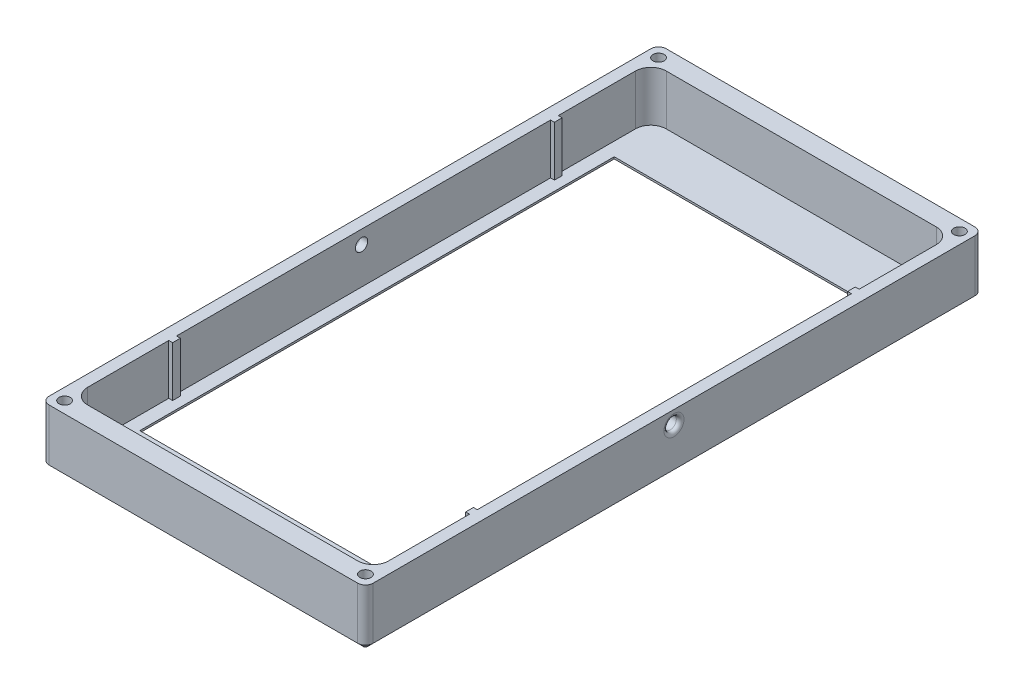
from build123d import *

# Parameters (mm, degrees)
EXTRUDE_2_DEPTH     = 15
FILLET_1_R          = 2
FILLET_2_R          = 2
FILLET_3_R          = 4
FILLET_4_R          = 4
EXTRUDE_3_DEPTH     = 15
FILLET_5_R          = 2
SKETCH_5_R          = 1.45
CUT_EXTRUDE_1_DEPTH = 10
EXTRUDE_4_DEPTH     = 2
SKETCH_9_R          = 1.6
CUT_EXTRUDE_3_DEPTH = 84
FILLET_6_R          = 1
FILLET_7_R          = 1
SKETCH_10_W         = 78
SKETCH_10_H         = 128
SKETCH_10_W_2       = 71
SKETCH_10_H_2       = 123
EXTRUDE_5_DEPTH     = 2
SKETCH_11_W         = 1
SKETCH_11_H         = 2
EXTRUDE_6_DEPTH     = 13
SKETCH_13_R         = 2.45
EXTRUDE_8_DEPTH     = 13
SKETCH_14_W         = 62.39543454
SKETCH_14_H         = 37.793362071
SKETCH_14_H_2       = 37.79336207
CUT_EXTRUDE_4_DEPTH = 15
EXTRUDE_9_DEPTH     = 15
SKETCH_16_R         = 1.45
CUT_EXTRUDE_5_DEPTH = 13
FILLET_8_R          = 2
CHAMFER_1_SIZE      = 1.5


with BuildPart() as part:
    # 草图3 → 凸台-拉伸2 (new body)
    with BuildSketch(Plane(origin=(0, 0, 0), x_dir=(1, 0, 0), z_dir=(0, 1, 0))):
        Polygon((-3, 1345.161797484), (-3, 1501.161797484), (17.145898034, 1501.161797484), (27.145898034, 1521.161797484), (50.854101966, 1521.161797484), (60.854101966, 1501.161797484), (81, 1501.161797484), (81, 1345.161797484), (60.854101966, 1345.161797484), (50.854101966, 1325.161797484), (27.145898034, 1325.161797484), (17.145898034, 1345.161797484), align=None)
        Polygon((49, 1518.161797484), (59, 1498.161797484), (78, 1498.161797484), (78, 1348.161797484), (59, 1348.161797484), (49, 1328.161797484), (29, 1328.161797484), (19, 1348.161797484), (0, 1348.161797484), (0, 1498.161797484), (19, 1498.161797484), (29, 1518.161797484), align=None, mode=Mode.SUBTRACT)
    extrude(amount=EXTRUDE_2_DEPTH)

    # 圆角1
    fillet_1_edges = [part.edges().sort_by_distance(p)[0] for p in [
        (49, 7.5, -1518.161797484),
        (29, 7.5, -1518.161797484),
        (19, 7.5, -1498.161797484),
        (59, 7.5, -1498.161797484),
        (17.145898034, 7.5, -1501.161797484),
        (27.145898034, 7.5, -1521.161797484),
        (50.854101966, 7.5, -1521.161797484),
        (60.854101966, 7.5, -1501.161797484),
    ]]
    fillet(fillet_1_edges, radius=FILLET_1_R)

    # 圆角2
    fillet_2_edges = [part.edges().sort_by_distance(p)[0] for p in [
        (19, 7.5, -1348.161797484),
        (29, 7.5, -1328.161797484),
        (49, 7.5, -1328.161797484),
        (59, 7.5, -1348.161797484),
        (60.854101966, 7.5, -1345.161797484),
        (50.854101966, 7.5, -1325.161797484),
        (27.145898034, 7.5, -1325.161797484),
        (17.145898034, 7.5, -1345.161797484),
    ]]
    fillet(fillet_2_edges, radius=FILLET_2_R)

    # 圆角3
    fillet_3_edges = [part.edges().sort_by_distance(p)[0] for p in [
        (-3, 7.5, -1501.161797484),
        (81, 7.5, -1501.161797484),
        (81, 7.5, -1345.161797484),
        (-3, 7.5, -1345.161797484),
    ]]
    fillet(fillet_3_edges, radius=FILLET_3_R)

    # 圆角4
    fillet_4_edges = [part.edges().sort_by_distance(p)[0] for p in [
        (0, 7.5, -1498.161797484),
        (0, 7.5, -1348.161797484),
        (78, 7.5, -1348.161797484),
        (78, 7.5, -1498.161797484),
    ]]
    fillet(fillet_4_edges, radius=FILLET_4_R)

    # 草图4 → 凸台-拉伸3 (add)
    with BuildSketch(Plane(origin=(0, 15, 0), x_dir=(1, 0, 0), z_dir=(0, 1, 0))):
        with BuildLine():
            Line((8.454915028, 1345.161797484), (22.145898034, 1335.161797484))
            Line((22.145898034, 1335.161797484), (17.698684438, 1344.056224675))
            ThreePointArc((17.698684438, 1344.056224675), (16.96129228, 1344.8630991), (15.909830056, 1345.161797484))
            Line((15.909830056, 1345.161797484), (8.454915028, 1345.161797484))
        make_face()
        with BuildLine():
            Line((69.545084972, 1345.161797484), (62.090169944, 1345.161797484))
            ThreePointArc((62.090169944, 1345.161797484), (61.03870772, 1344.8630991), (60.301315562, 1344.056224675))
            Line((60.301315562, 1344.056224675), (55.854101966, 1335.161797484))
            Line((55.854101966, 1335.161797484), (69.545084972, 1345.161797484))
        make_face()
        with BuildLine():
            Line((69.545084972, 1501.161797484), (55.854101966, 1511.161797484))
            Line((55.854101966, 1511.161797484), (60.301315562, 1502.267370293))
            ThreePointArc((60.301315562, 1502.267370293), (61.03870772, 1501.460495867), (62.090169944, 1501.161797484))
            Line((62.090169944, 1501.161797484), (69.545084972, 1501.161797484))
        make_face()
        with BuildLine():
            Line((8.454915028, 1501.161797484), (15.909830056, 1501.161797484))
            ThreePointArc((15.909830056, 1501.161797484), (16.96129228, 1501.460495867), (17.698684438, 1502.267370293))
            Line((17.698684438, 1502.267370293), (22.145898034, 1511.161797484))
            Line((22.145898034, 1511.161797484), (8.454915028, 1501.161797484))
        make_face()
    extrude(amount=-EXTRUDE_3_DEPTH)

    # 圆角5
    fillet_5_edges = [part.edges().sort_by_distance(p)[0] for p in [
        (8.454915028, 7.5, -1345.161797484),
        (22.145898034, 7.5, -1335.161797484),
        (69.545084972, 7.5, -1345.161797484),
        (55.854101966, 7.5, -1335.161797484),
        (55.854101966, 7.5, -1511.161797484),
        (69.545084972, 7.5, -1501.161797484),
        (8.454915028, 7.5, -1501.161797484),
        (22.145898034, 7.5, -1511.161797484),
    ]]
    fillet(fillet_5_edges, radius=FILLET_5_R)

    # 草图5 → 切除-拉伸1 (cut)
    with BuildSketch(Plane(origin=(0, 15, 0), x_dir=(1, 0, 0), z_dir=(0, 1, 0))):
        with Locations((16, 1344.661797484)):
            Circle(SKETCH_5_R)
        with Locations((62, 1344.661797484)):
            Circle(SKETCH_5_R)
        with Locations((62, 1501.661797484)):
            Circle(SKETCH_5_R)
        with Locations((16, 1501.661797484)):
            Circle(SKETCH_5_R)
    extrude(amount=-CUT_EXTRUDE_1_DEPTH, mode=Mode.SUBTRACT)

    # 草图6 → 凸台-拉伸4 (add)
    with BuildSketch(Plane.XZ):
        with BuildLine():
            Line((70.19771727, -1501.161797484), (77, -1501.161797484))
            ThreePointArc((77, -1501.161797484), (79.828427125, -1499.990224608), (81, -1497.161797484))
            Line((81, -1497.161797484), (81, -1487.161797484))
            Line((81, -1487.161797484), (-3, -1487.161797484))
            Line((-3, -1487.161797484), (-3, -1497.161797484))
            ThreePointArc((-3, -1497.161797484), (-1.828427125, -1499.990224608), (1, -1501.161797484))
            Line((1, -1501.161797484), (7.80228273, -1501.161797484))
            ThreePointArc((7.80228273, -1501.161797484), (8.422717804, -1501.260466287), (8.981935292, -1501.546737165))
            Line((8.981935292, -1501.546737165), (21.753826871, -1510.875425671))
            ThreePointArc((21.753826871, -1510.875425671), (22.101536871, -1511.199299092), (22.363028691, -1511.596058798))
            Line((22.363028691, -1511.596058798), (26.593111629, -1520.056224675))
            ThreePointArc((26.593111629, -1520.056224675), (27.330503787, -1520.8630991), (28.381966011, -1521.161797484))
            Line((28.381966011, -1521.161797484), (49.618033989, -1521.161797484))
            ThreePointArc((49.618033989, -1521.161797484), (50.669496213, -1520.8630991), (51.406888371, -1520.056224675))
            Line((51.406888371, -1520.056224675), (55.636971309, -1511.596058798))
            ThreePointArc((55.636971309, -1511.596058798), (55.898463129, -1511.199299092), (56.246173129, -1510.875425671))
            Line((56.246173129, -1510.875425671), (69.018064708, -1501.546737165))
            ThreePointArc((69.018064708, -1501.546737165), (69.577282196, -1501.260466287), (70.19771727, -1501.161797484))
        make_face()
        with BuildLine():
            Line((81, -1349.161797484), (81, -1359.161797484))
            Line((81, -1359.161797484), (-3, -1359.161797484))
            Line((-3, -1359.161797484), (-3, -1349.161797484))
            ThreePointArc((-3, -1349.161797484), (-1.828427125, -1346.333370359), (1, -1345.161797484))
            Line((1, -1345.161797484), (7.80228273, -1345.161797484))
            ThreePointArc((7.80228273, -1345.161797484), (8.422717804, -1345.06312868), (8.981935292, -1344.776857802))
            Line((8.981935292, -1344.776857802), (21.753826871, -1335.448169296))
            ThreePointArc((21.753826871, -1335.448169296), (22.101536871, -1335.124295876), (22.363028691, -1334.727536169))
            Line((22.363028691, -1334.727536169), (26.593111629, -1326.267370293))
            ThreePointArc((26.593111629, -1326.267370293), (27.330503787, -1325.460495867), (28.381966011, -1325.161797484))
            Line((28.381966011, -1325.161797484), (49.618033989, -1325.161797484))
            ThreePointArc((49.618033989, -1325.161797484), (50.669496213, -1325.460495867), (51.406888371, -1326.267370293))
            Line((51.406888371, -1326.267370293), (55.636971309, -1334.727536169))
            ThreePointArc((55.636971309, -1334.727536169), (55.898463129, -1335.124295876), (56.246173129, -1335.448169296))
            Line((56.246173129, -1335.448169296), (69.018064708, -1344.776857802))
            ThreePointArc((69.018064708, -1344.776857802), (69.577282196, -1345.06312868), (70.19771727, -1345.161797484))
            Line((70.19771727, -1345.161797484), (77, -1345.161797484))
            ThreePointArc((77, -1345.161797484), (79.828427125, -1346.333370359), (81, -1349.161797484))
        make_face()
    extrude(amount=-EXTRUDE_4_DEPTH)

    # 草图9 → 切除-拉伸3 (cut)
    with BuildSketch(Plane(origin=(81, 0, 0), x_dir=(0, 0, -1), z_dir=(1, 0, 0))):
        with Locations((1423.161797484, 11.5)):
            Circle(SKETCH_9_R)
    extrude(amount=-CUT_EXTRUDE_3_DEPTH, mode=Mode.SUBTRACT)

    # 圆角6
    fillet_6_edges = [part.edges().sort_by_distance(p)[0] for p in [
        (-3, 11.5, -1421.561797484),
        (81, 11.5, -1421.561797484),
    ]]
    fillet(fillet_6_edges, radius=FILLET_6_R)

    # 圆角7
    fillet_7_edges = [part.edges().sort_by_distance(p)[0] for p in [
        (14.55, 15, -1501.661797484),
        (60.55, 15, -1501.661797484),
        (60.55, 15, -1344.661797484),
        (14.55, 15, -1344.661797484),
    ]]
    fillet(fillet_7_edges, radius=FILLET_7_R)

    # 草图10 → 凸台-拉伸5 (add)
    with BuildSketch(Plane.XZ):
        with Locations((39, -1423.161797484)):
            Rectangle(SKETCH_10_W, SKETCH_10_H)
        with Locations((39, -1423.661797484)):
            Rectangle(SKETCH_10_W_2, SKETCH_10_H_2, mode=Mode.SUBTRACT)
    extrude(amount=-EXTRUDE_5_DEPTH)

    # 草图11 → 凸台-拉伸6 (add)
    with BuildSketch(Plane(origin=(0, 2, 0), x_dir=(1, 0, 0), z_dir=(0, 1, 0))):
        with Locations((77.5, 1374.161797484)):
            Rectangle(SKETCH_11_W, SKETCH_11_H)
        with Locations((0.5, 1374.161797484)):
            Rectangle(SKETCH_11_W, SKETCH_11_H)
        with Locations((0.5, 1473.161797484)):
            Rectangle(SKETCH_11_W, SKETCH_11_H)
        with Locations((77.5, 1473.161797484)):
            Rectangle(SKETCH_11_W, SKETCH_11_H)
    extrude(amount=EXTRUDE_6_DEPTH)

    # 草图13 → 凸台-拉伸8 (add)
    with BuildSketch(Plane(origin=(0, 15, 0), x_dir=(1, 0, 0), z_dir=(0, 1, 0))):
        with Locations((62, 1501.661797484)):
            Circle(SKETCH_13_R)
        with Locations((16, 1501.661797484)):
            Circle(SKETCH_13_R)
        with Locations((62, 1344.661797484)):
            Circle(SKETCH_13_R)
        with Locations((16, 1344.661797484)):
            Circle(SKETCH_13_R)
    extrude(amount=-EXTRUDE_8_DEPTH)

    # 草图14 → 切除-拉伸4 (cut)
    with BuildSketch(Plane(origin=(0, 15, 0), x_dir=(1, 0, 0), z_dir=(0, 1, 0))):
        with Locations((39, 1326.265116449)):
            Rectangle(SKETCH_14_W, SKETCH_14_H)
        with Locations((39, 1520.058478519)):
            Rectangle(SKETCH_14_W, SKETCH_14_H_2)
    extrude(amount=-CUT_EXTRUDE_4_DEPTH, mode=Mode.SUBTRACT)

    # 草图15 → 凸台-拉伸9 (add)
    with BuildSketch(Plane(origin=(0, 15, 0), x_dir=(1, 0, 0), z_dir=(0, 1, 0))):
        Polygon((-3, 1348.161797484), (-3, 1343.161797484), (81, 1343.161797484), (81, 1348.161797484), (81, 1352.401319515), (79.302833031, 1352.401319515), (79.302833031, 1348.161797484), (-0.854989164, 1348.161797484), (-0.854989164, 1353.161797484), (-3, 1353.161797484), align=None)
        Polygon((79.302833031, 1493.922275452), (79.302833031, 1498.161797484), (-0.854989164, 1498.161797484), (-0.854989164, 1493.161797484), (-3, 1493.161797484), (-3, 1498.161797484), (-3, 1503.161797484), (81, 1503.161797484), (81, 1498.161797484), (81, 1493.922275452), align=None)
    extrude(amount=-EXTRUDE_9_DEPTH)

    # 草图16 → 切除-拉伸5 (cut)
    with BuildSketch(Plane(origin=(0, 15, 0), x_dir=(1, 0, 0), z_dir=(0, 1, 0))):
        with Locations((0, 1346.161797484)):
            Circle(SKETCH_16_R)
        with Locations((0, 1500.161797484)):
            Circle(SKETCH_16_R)
        with Locations((78, 1500.161797484)):
            Circle(SKETCH_16_R)
        with Locations((78, 1346.161797484)):
            Circle(SKETCH_16_R)
    extrude(amount=-CUT_EXTRUDE_5_DEPTH, mode=Mode.SUBTRACT)

    # 圆角8
    fillet_8_edges = [part.edges().sort_by_distance(p)[0] for p in [
        (81, 7.5, -1343.161797484),
        (-3, 7.5, -1343.161797484),
        (-3, 7.5, -1503.161797484),
        (81, 7.5, -1503.161797484),
    ]]
    fillet(fillet_8_edges, radius=FILLET_8_R)

    # 倒角1
    chamfer_1_edges = [part.edges().sort_by_distance(p)[0] for p in [
        (74.5, 0, -1423.661797484),
        (39, 0, -1485.161797484),
        (3.5, 0, -1423.661797484),
        (39, 0, -1362.161797484),
        (81, 0, -1423.161797484),
        (39, 0, -1503.161797484),
        (39, 0, -1343.161797484),
        (-3, 0, -1423.161797484),
        (80.414213562, 0, -1343.747583921),
        (-2.414213562, 0, -1343.747583921),
        (-2.414213562, 0, -1502.576011046),
        (80.414213562, 0, -1502.576011046),
    ]]
    chamfer(chamfer_1_edges, length=CHAMFER_1_SIZE)


solid = part.part
